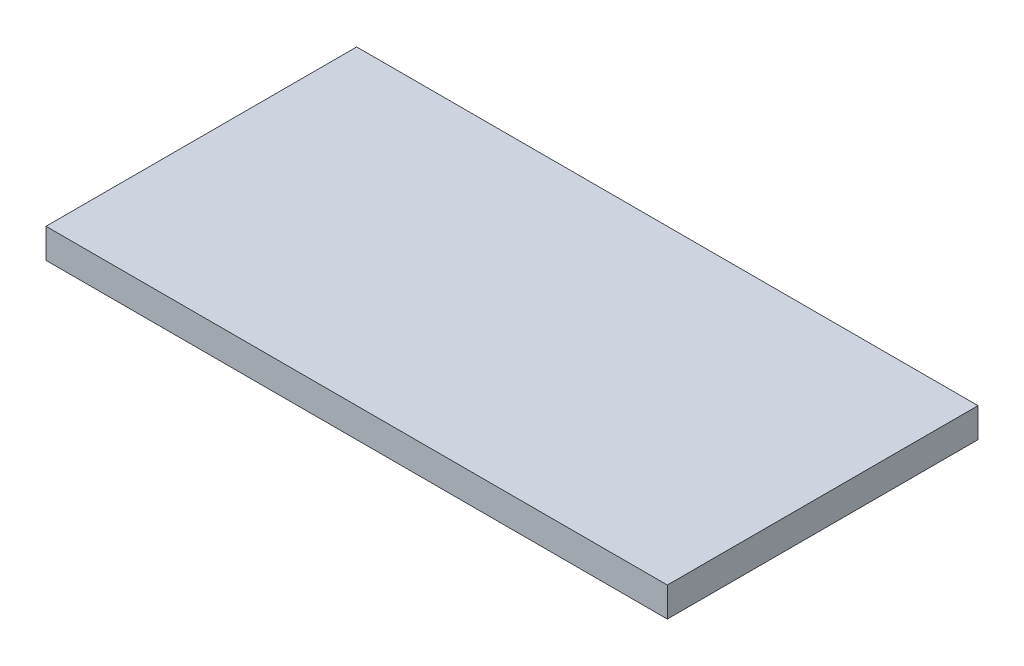
from build123d import *

# Parameters (mm, degrees)
SKETCH1_W           = 400
SKETCH1_H           = 200
BOSS_EXTRUDE1_DEPTH = 19


with BuildPart() as part:
    # Sketch1 → Boss-Extrude1 (new body)
    with BuildSketch(Plane(origin=(0, 0, 0), x_dir=(1, 0, 0), z_dir=(0, 1, 0))):
        Rectangle(SKETCH1_W, SKETCH1_H)
    extrude(amount=-BOSS_EXTRUDE1_DEPTH)


solid = part.part
